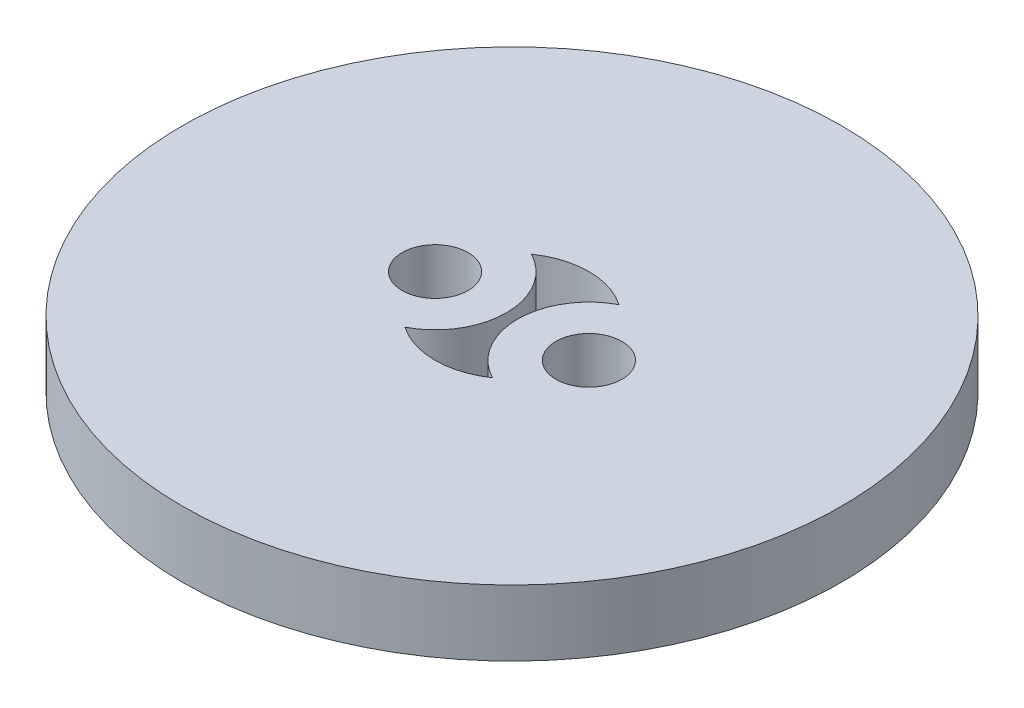
from build123d import *

# Parameters (mm, degrees)
ESQUISSE1_R        = 15
ESQUISSE1_R_2      = 1.5
BOSS_EXTRU_1_DEPTH = 3


with BuildPart() as part:
    # Esquisse1 → Boss.-Extru.1 (new body)
    with BuildSketch(Plane(origin=(0, 0, 0), x_dir=(1, 0, 0), z_dir=(0, 1, 0))):
        Circle(ESQUISSE1_R)
        with Locations((-3.5, 0)):
            Circle(ESQUISSE1_R_2, mode=Mode.SUBTRACT)
        with Locations((3.5, 0)):
            Circle(ESQUISSE1_R_2, mode=Mode.SUBTRACT)
        with BuildLine():
            ThreePointArc((1.991071429, 2.878477821), (0.25, 0), (1.991071429, -2.878477821))
            ThreePointArc((1.991071429, -2.878477821), (0, -3.5), (-1.991071429, -2.878477821))
            ThreePointArc((-1.991071429, -2.878477821), (-0.25, 0), (-1.991071429, 2.878477821))
            ThreePointArc((-1.991071429, 2.878477821), (0, 3.5), (1.991071429, 2.878477821))
        make_face(mode=Mode.SUBTRACT)
    extrude(amount=BOSS_EXTRU_1_DEPTH)


solid = part.part
